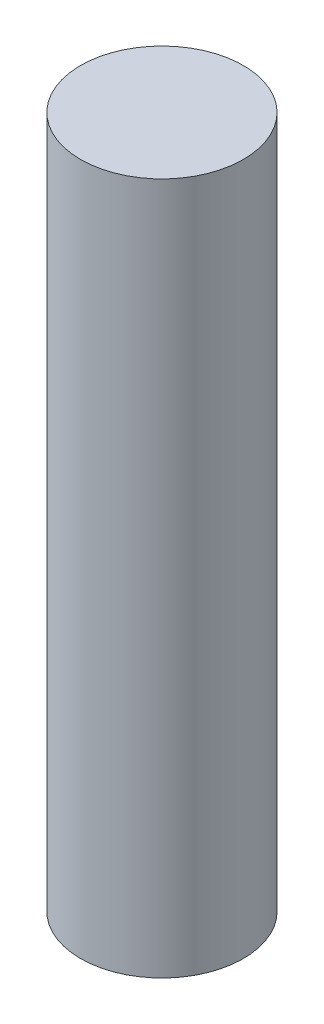
from build123d import *

# Parameters (mm, degrees)
SKETCH1_R           = 2
BOSS_EXTRUDE1_DEPTH = 17


with BuildPart() as part:
    # Sketch1 → Boss-Extrude1 (new body)
    with BuildSketch(Plane(origin=(0, 0, 0), x_dir=(1, 0, 0), z_dir=(0, 1, 0))):
        Circle(SKETCH1_R)
    extrude(amount=BOSS_EXTRUDE1_DEPTH)


solid = part.part
